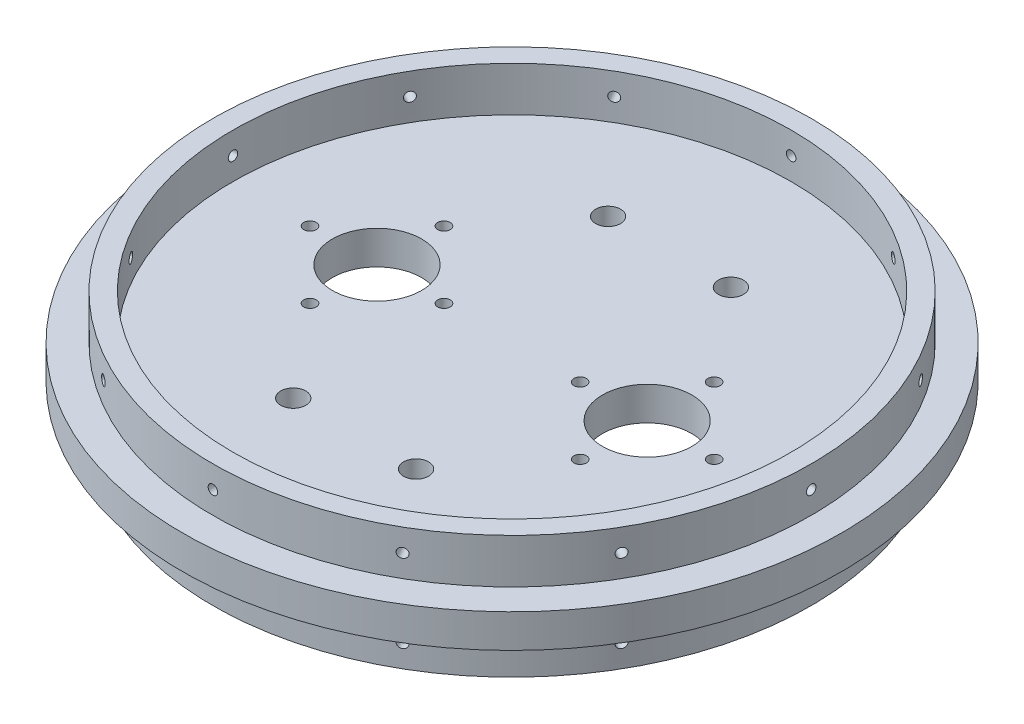
from build123d import *

# Parameters (mm, degrees)
SKETCH1_W           = 127.635
SKETCH1_H           = 127.635
BOSS_EXTRUDE1_DEPTH = 9.525
SKETCH12_R          = 93.726
BOSS_EXTRUDE2_DEPTH = 9.525
SKETCH30_R          = 85.09
SKETCH30_R_2        = 79.375
BOSS_EXTRUDE3_DEPTH = 12.7
SKETCH32_R          = 1.35255
CUT_EXTRUDE4_DEPTH  = 15.24
CIRPATTERN2_COUNT   = 12
SKETCH35_R          = 12.7
SKETCH35_R_2        = 1.778
CO2_MOUNTS_DEPTH    = 23.2250001
SKETCH36_R          = 3.556
U_BOLT_MOUNTS_DEPTH = 23.2250001


with BuildPart() as part:
    # Sketch1 → Boss-Extrude1 (new body)
    with BuildSketch(Plane(origin=(0, 0, 0), x_dir=(1, 0, 0), z_dir=(0, 1, 0))):
        with Locations((63.8175, 63.8175)):
            Rectangle(SKETCH1_W, SKETCH1_H)
    extrude(amount=BOSS_EXTRUDE1_DEPTH)

    # Sketch12 → Boss-Extrude2 (add)
    with BuildSketch(Plane.XZ):
        with Locations((63.8175, -63.8175)):
            Circle(SKETCH12_R)
    extrude(amount=-BOSS_EXTRUDE2_DEPTH)

    # Sketch30 → Boss-Extrude3 (add)
    with BuildSketch(Plane.XZ):
        with Locations((63.8175, -63.8175)):
            Circle(SKETCH30_R)
        with Locations((63.8175, -63.8175)):
            Circle(SKETCH30_R_2, mode=Mode.SUBTRACT)
    boss_extrude3 = extrude(amount=BOSS_EXTRUDE3_DEPTH)

    # Mirror1: Boss-Extrude3 across plane
    add(boss_extrude3.mirror(Plane.ZX.offset(4.7625)))

    # Sketch32 → Cut-Extrude4 (cut)
    with BuildSketch(Plane(origin=(0, 0, -148.9075), x_dir=(-1, 0, 0), z_dir=(0, 0, -1))):
        with Locations((-63.8175, -6.35)):
            Circle(SKETCH32_R)
        with Locations((-63.8175, 15.875)):
            Circle(SKETCH32_R)
    cut_extrude4 = extrude(amount=-CUT_EXTRUDE4_DEPTH, mode=Mode.SUBTRACT)

    # CirPattern2: Cut-Extrude4 ×12 about axis
    cirpattern2_axis = Axis((63.8175, -12.7, -63.8175), (0, 1, 0))
    for i in range(1, CIRPATTERN2_COUNT):
        add(cut_extrude4.rotate(cirpattern2_axis, i * 360 / CIRPATTERN2_COUNT), mode=Mode.SUBTRACT)

    # Sketch35 → Co2 mounts (cut, through all)
    with BuildSketch(Plane.XZ):
        with Locations((25.4, -63.8175)):
            Circle(SKETCH35_R)
        with Locations((25.4, -44.7675)):
            Circle(SKETCH35_R_2)
        with Locations((44.45, -63.8175)):
            Circle(SKETCH35_R_2)
        with Locations((25.4, -82.8675)):
            Circle(SKETCH35_R_2)
        with Locations((6.35, -63.8175)):
            Circle(SKETCH35_R_2)
        with Locations((102.235, -44.7675)):
            Circle(SKETCH35_R_2)
        with Locations((83.185, -63.8175)):
            Circle(SKETCH35_R_2)
        with Locations((102.235, -82.8675)):
            Circle(SKETCH35_R_2)
        with Locations((121.285, -63.8175)):
            Circle(SKETCH35_R_2)
        with Locations((102.235, -63.8175)):
            Circle(SKETCH35_R)
    extrude(amount=-CO2_MOUNTS_DEPTH, mode=Mode.SUBTRACT)

    # Sketch36 → U bolt mounts (cut, through all)
    with BuildSketch(Plane.XZ):
        with Locations((81.28, -108.585)):
            Circle(SKETCH36_R)
        with Locations((46.355, -108.585)):
            Circle(SKETCH36_R)
        with Locations((46.355, -19.05)):
            Circle(SKETCH36_R)
        with Locations((81.28, -19.05)):
            Circle(SKETCH36_R)
    extrude(amount=-U_BOLT_MOUNTS_DEPTH, mode=Mode.SUBTRACT)


solid = part.part
